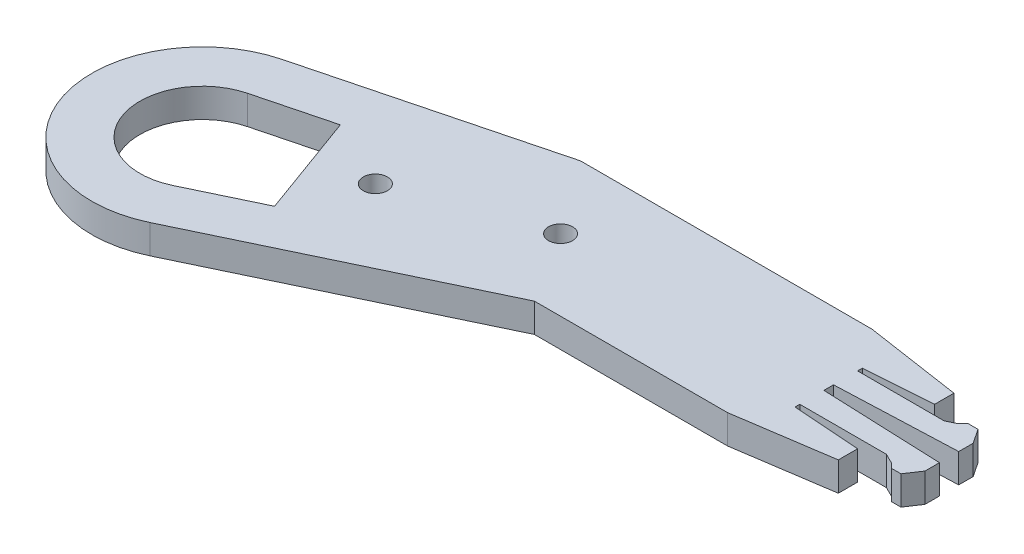
from build123d import *

# Parameters (mm, degrees)
SKETCH4_R           = 1.25
BOSS_EXTRUDE2_DEPTH = 3


with BuildPart() as part:
    # Sketch4 → Boss-Extrude2 (new body)
    with BuildSketch(Plane(origin=(0, 0, 0), x_dir=(1, 0, 0), z_dir=(0, 1, 0))):
        with BuildLine():
            Line((-2.879370047, 11.133697864), (21.737293787, 17.5))
            Line((21.737293787, 17.5), (52, 17.5))
            Line((52, 17.5), (62, 16))
            Line((62, 16), (62, 14))
            Line((62, 14), (55, 13.5))
            Line((55, 13.5), (55, 13))
            Line((55, 13), (64, 13))
            Line((64, 13), (65, 13.5))
            Line((65, 13.5), (65.5, 14))
            Line((65.5, 14), (66.5, 14))
            Line((66.5, 14), (67.5, 12.5))
            Line((67.5, 12.5), (67.5, 11))
            Line((67.5, 11), (55, 10.5))
            Line((55, 10.5), (55, 9.5))
            Line((55, 9.5), (67.5, 9))
            Line((67.5, 9), (67.5, 7.5))
            Line((67.5, 7.5), (66.5, 6))
            Line((66.5, 6), (65.5, 6))
            Line((65.5, 6), (65, 6.5))
            Line((65, 6.5), (64, 7))
            Line((64, 7), (55, 7))
            Line((55, 7), (55, 6.5))
            Line((55, 6.5), (62, 6))
            Line((62, 6), (62, 4))
            Line((62, 4), (52, 2.5))
            Line((52, 2.5), (31.953794717, 2.5))
            Line((31.953794717, 2.5), (4.950877613, -10.37973077))
            ThreePointArc((4.950877613, -10.37973077), (-10.806465139, -3.933231648), (-2.879370047, 11.133697864))
        make_face()
        with Locations((13.155696691, 4.788282007)):
            Circle(SKETCH4_R, mode=Mode.SUBTRACT)
        with Locations((27.251086003, 9.918584156)):
            Circle(SKETCH4_R, mode=Mode.SUBTRACT)
        with BuildLine():
            Line((6.033902904, 8.274325422), (9.94087165, -2.459982986))
            Line((9.94087165, -2.459982986), (2.798322129, -5.866804348))
            ThreePointArc((2.798322129, -5.866804348), (-6.108002035, -2.223130932), (-1.627470026, 6.292959662))
            Line((-1.627470026, 6.292959662), (6.033902904, 8.274325422))
        make_face(mode=Mode.SUBTRACT)
    extrude(amount=-BOSS_EXTRUDE2_DEPTH)


solid = part.part
